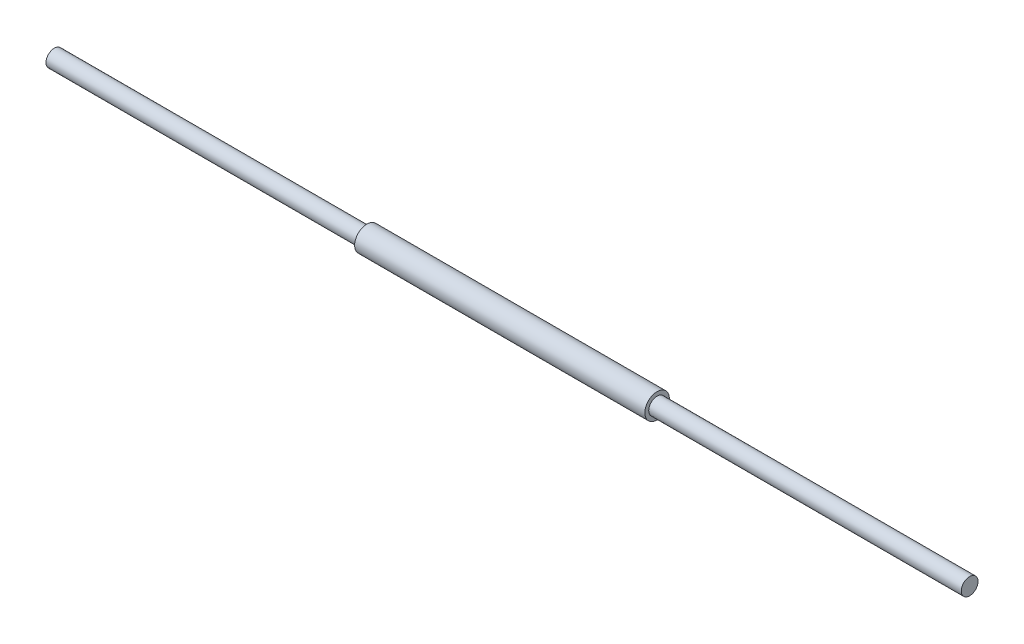
from build123d import *


with BuildPart() as part:
    # Sketch1 → Revolve1 (revolve)
    with BuildSketch(Plane.XY):
        Polygon((-260.35, 4.7625), (-82.55, 4.7625), (-82.55, 6.985), (82.55, 6.985), (82.55, 4.7625), (260.35, 4.7625), (260.35, 0), (-260.35, 0), align=None)
    revolve(axis=Axis((-260.35, 0, 0), (1, 0, 0)))


solid = part.part
